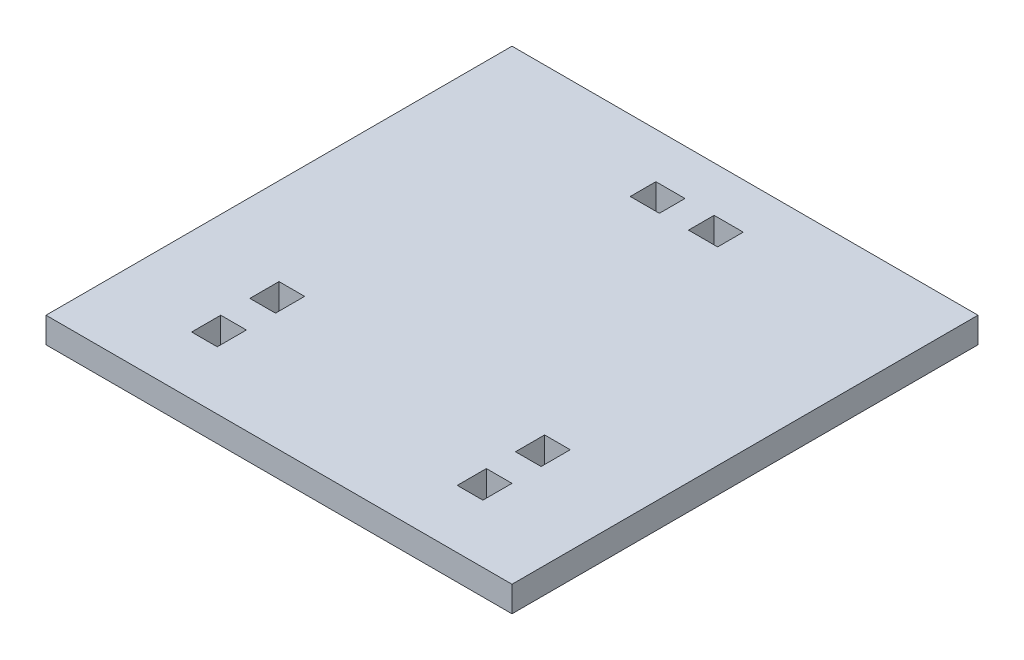
from build123d import *

# Parameters (mm, degrees)
SKETCH1_W           = 101.6
SKETCH1_H           = 101.6
SKETCH1_W_2         = 5.588
SKETCH1_H_2         = 6.35
SKETCH1_W_3         = 6.35
SKETCH1_H_3         = 5.588
BOSS_EXTRUDE1_DEPTH = 5.588


with BuildPart() as part:
    # Sketch1 → Boss-Extrude1 (new body)
    with BuildSketch(Plane(origin=(0, 0, 0), x_dir=(1, 0, 0), z_dir=(0, 1, 0))):
        with Locations((50.8, 50.8)):
            Rectangle(SKETCH1_W, SKETCH1_H)
        with Locations((79.756, 15.875)):
            Rectangle(SKETCH1_W_2, SKETCH1_H_2, mode=Mode.SUBTRACT)
        with Locations((21.844, 28.575)):
            Rectangle(SKETCH1_W_2, SKETCH1_H_2, mode=Mode.SUBTRACT)
        with Locations((21.844, 15.875)):
            Rectangle(SKETCH1_W_2, SKETCH1_H_2, mode=Mode.SUBTRACT)
        with Locations((79.756, 28.575)):
            Rectangle(SKETCH1_W_2, SKETCH1_H_2, mode=Mode.SUBTRACT)
        with Locations((44.45, 88.9)):
            Rectangle(SKETCH1_W_3, SKETCH1_H_3, mode=Mode.SUBTRACT)
        with Locations((57.15, 88.9)):
            Rectangle(SKETCH1_W_3, SKETCH1_H_3, mode=Mode.SUBTRACT)
    extrude(amount=BOSS_EXTRUDE1_DEPTH)


solid = part.part
